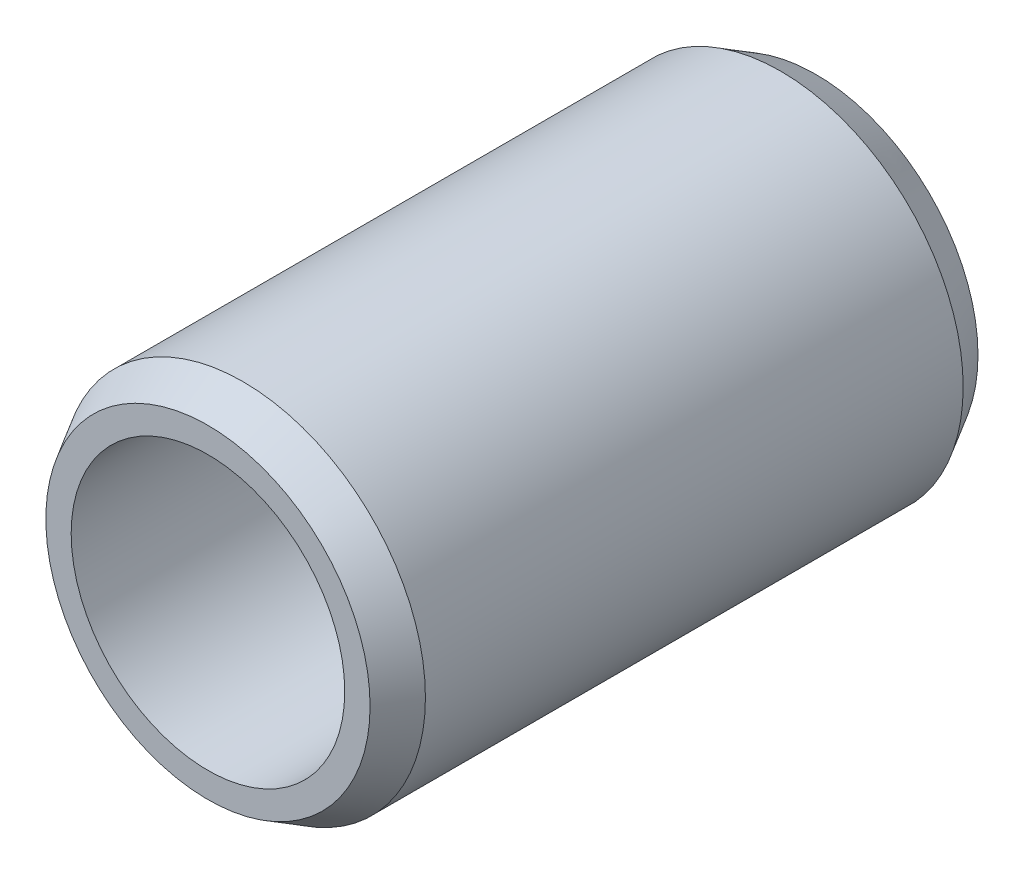
from build123d import *

# Parameters (mm, degrees)
SKETCH1_R             = 4.5
SKETCH1_R_2           = 3.375
BOSS_EXTRUDE1_DEPTH   = 15
CHAMFER1_SIZE         = 0.5
CHAMFER1_SIZE2        = 0.866025404
CHAMFER1_PART_2_SIZE  = 0.5
CHAMFER1_PART_2_SIZE2 = 0.866025404


with BuildPart() as part:
    # Sketch1 → Boss-Extrude1 (new body)
    with BuildSketch(Plane.XY):
        Circle(SKETCH1_R)
        Circle(SKETCH1_R_2, mode=Mode.SUBTRACT)
    extrude(amount=BOSS_EXTRUDE1_DEPTH)

    # Chamfer1
    chamfer1_edges = [part.edges().sort_by_distance(p)[0] for p in [
        (-4.5, 0, 0),
    ]]
    chamfer1_side = [part.faces().sort_by_distance(p)[0] for p in [
        (-4.372720779, 0, 0),
    ]]
    chamfer(chamfer1_edges, length=CHAMFER1_SIZE, length2=CHAMFER1_SIZE2, reference=chamfer1_side[0])

    # Chamfer1 part 2
    chamfer1_part_2_edges = [part.edges().sort_by_distance(p)[0] for p in [
        (-4.5, 0, 15),
    ]]
    chamfer1_part_2_side = [part.faces().sort_by_distance(p)[0] for p in [
        (-4.372720779, 0, 15),
    ]]
    chamfer(chamfer1_part_2_edges, length=CHAMFER1_PART_2_SIZE, length2=CHAMFER1_PART_2_SIZE2, reference=chamfer1_part_2_side[0])


solid = part.part
